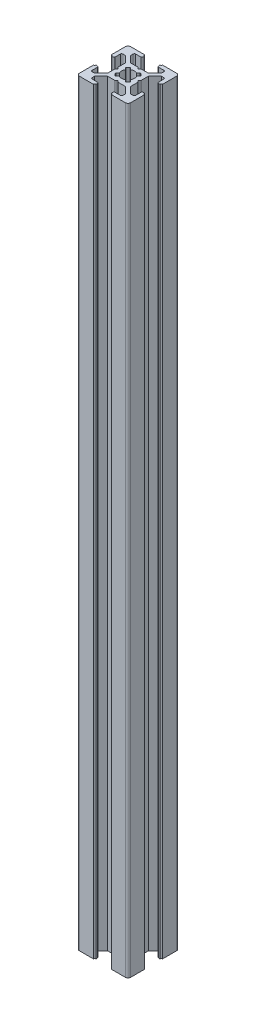
from build123d import *

# Parameters (mm, degrees)
BOSS_EXTRUDE1_DEPTH = 296
FILLET1_R           = 1
CUT_EXTRUDE1_DEPTH  = 297
FILLET2_R           = 0.5
FILLET3_R           = 0.25


with BuildPart() as part:
    # Sketch3 → Boss-Extrude1 (new body)
    with BuildSketch(Plane(origin=(0, 0, 0), x_dir=(1, 0, 0), z_dir=(0, 1, 0))):
        with BuildLine():
            Line((7, 18.5), (7, 19.5))
            ThreePointArc((7, 19.5), (6.646446609, 19.646446609), (6.5, 20))
            Line((6.5, 20), (0, 20))
            Line((0, 20), (0, 13.5))
            ThreePointArc((0, 13.5), (0.353553391, 13.353553391), (0.5, 13))
            Line((0.5, 13), (1.5, 13))
            Line((1.5, 13), (1.5, 16))
            Line((1.5, 16), (3, 16))
            Line((3, 16), (5.5, 13.5))
            Line((5.5, 13.5), (5.5, 10.5))
            Line((5.5, 10.5), (6, 10))
            Line((6, 10), (5.5, 9.5))
            Line((5.5, 9.5), (5.5, 6.5))
            Line((5.5, 6.5), (3, 4))
            Line((3, 4), (1.5, 4))
            Line((1.5, 4), (1.5, 7))
            Line((1.5, 7), (0.5, 7))
            ThreePointArc((0.5, 7), (0.353553391, 6.646446609), (0, 6.5))
            Line((0, 6.5), (0, 0))
            Line((0, 0), (6.5, 0))
            ThreePointArc((6.5, 0), (6.646446609, 0.353553391), (7, 0.5))
            Line((7, 0.5), (7, 1.5))
            Line((7, 1.5), (4, 1.5))
            Line((4, 1.5), (4, 3))
            Line((4, 3), (6.5, 5.5))
            Line((6.5, 5.5), (9.5, 5.5))
            Line((9.5, 5.5), (10, 6))
            Line((10, 6), (10.5, 5.5))
            Line((10.5, 5.5), (13.5, 5.5))
            Line((13.5, 5.5), (16, 3))
            Line((16, 3), (16, 1.5))
            Line((16, 1.5), (13, 1.5))
            Line((13, 1.5), (13, 0.5))
            ThreePointArc((13, 0.5), (13.353553391, 0.353553391), (13.5, 0))
            Line((13.5, 0), (20, 0))
            Line((20, 0), (20, 6.5))
            ThreePointArc((20, 6.5), (19.646446609, 6.646446609), (19.5, 7))
            Line((19.5, 7), (18.5, 7))
            Line((18.5, 7), (18.5, 4))
            Line((18.5, 4), (17, 4))
            Line((17, 4), (14.5, 6.5))
            Line((14.5, 6.5), (14.5, 9.5))
            Line((14.5, 9.5), (14, 10))
            Line((14, 10), (14.5, 10.5))
            Line((14.5, 10.5), (14.5, 13.5))
            Line((14.5, 13.5), (17, 16))
            Line((17, 16), (18.5, 16))
            Line((18.5, 16), (18.5, 13))
            Line((18.5, 13), (19.5, 13))
            ThreePointArc((19.5, 13), (19.646446609, 13.353553391), (20, 13.5))
            Line((20, 13.5), (20, 20))
            Line((20, 20), (13.5, 20))
            ThreePointArc((13.5, 20), (13.353553391, 19.646446609), (13, 19.5))
            Line((13, 19.5), (13, 18.5))
            Line((13, 18.5), (16, 18.5))
            Line((16, 18.5), (16, 17))
            Line((16, 17), (13.5, 14.5))
            Line((13.5, 14.5), (10.5, 14.5))
            Line((10.5, 14.5), (10, 14))
            Line((10, 14), (9.5, 14.5))
            Line((9.5, 14.5), (6.5, 14.5))
            Line((6.5, 14.5), (4, 17))
            Line((4, 17), (4, 18.5))
            Line((4, 18.5), (7, 18.5))
        make_face()
    extrude(amount=BOSS_EXTRUDE1_DEPTH)

    # Fillet1
    fillet1_edges = [part.edges().sort_by_distance(p)[0] for p in [
        (20, 148, 0),
        (0, 148, 0),
        (0, 148, -20),
        (20, 148, -20),
    ]]
    fillet(fillet1_edges, radius=FILLET1_R)

    # Sketch4 → Cut-Extrude1 (cut, through all)
    with BuildSketch(Plane(origin=(0, 296, 0), x_dir=(1, 0, 0), z_dir=(0, 1, 0))):
        with BuildLine():
            Line((10, 11), (11.195582496, 12.195582496))
            ThreePointArc((11.195582496, 12.195582496), (10, 12.5), (8.804417504, 12.195582496))
            Line((8.804417504, 12.195582496), (10, 11))
        make_face()
        with BuildLine():
            ThreePointArc((12.195582496, 11.195582496), (11.767766953, 11.767766953), (11.195582496, 12.195582496))
            Line((11.195582496, 12.195582496), (10, 11))
            Line((10, 11), (11, 10))
            Line((11, 10), (12.195582496, 11.195582496))
        make_face()
        with BuildLine():
            Line((9, 10), (10, 11))
            Line((10, 11), (8.804417504, 12.195582496))
            ThreePointArc((8.804417504, 12.195582496), (8.232233047, 11.767766953), (7.804417504, 11.195582496))
            Line((7.804417504, 11.195582496), (9, 10))
        make_face()
        Polygon((11, 10), (10, 11), (9, 10), (10, 9), align=None)
        with BuildLine():
            Line((7.804417504, 8.804417504), (9, 10))
            Line((9, 10), (7.804417504, 11.195582496))
            ThreePointArc((7.804417504, 11.195582496), (7.5, 10), (7.804417504, 8.804417504))
        make_face()
        with BuildLine():
            Line((10, 9), (9, 10))
            Line((9, 10), (7.804417504, 8.804417504))
            ThreePointArc((7.804417504, 8.804417504), (8.232233047, 8.232233047), (8.804417504, 7.804417504))
            Line((8.804417504, 7.804417504), (10, 9))
        make_face()
        with BuildLine():
            Line((11.195582496, 7.804417504), (10, 9))
            Line((10, 9), (8.804417504, 7.804417504))
            ThreePointArc((8.804417504, 7.804417504), (10, 7.5), (11.195582496, 7.804417504))
        make_face()
        with BuildLine():
            Line((12.195582496, 8.804417504), (11, 10))
            Line((11, 10), (10, 9))
            Line((10, 9), (11.195582496, 7.804417504))
            ThreePointArc((11.195582496, 7.804417504), (11.767766953, 8.232233047), (12.195582496, 8.804417504))
        make_face()
        with BuildLine():
            ThreePointArc((12.5, 10), (12.422700584, 10.616864556), (12.195582496, 11.195582496))
            Line((12.195582496, 11.195582496), (11, 10))
            Line((11, 10), (12.195582496, 8.804417504))
            ThreePointArc((12.195582496, 8.804417504), (12.422700584, 9.383135444), (12.5, 10))
        make_face()
        with BuildLine():
            ThreePointArc((8.804417504, 7.804417504), (8.232233047, 8.232233047), (7.804417504, 8.804417504))
            Line((7.804417504, 8.804417504), (7, 8))
            Line((7, 8), (8, 7))
            Line((8, 7), (8.804417504, 7.804417504))
        make_face()
        with BuildLine():
            Line((13, 8), (12.195582496, 8.804417504))
            ThreePointArc((12.195582496, 8.804417504), (11.767766953, 8.232233047), (11.195582496, 7.804417504))
            Line((11.195582496, 7.804417504), (12, 7))
            Line((12, 7), (13, 8))
        make_face()
        with BuildLine():
            Line((13, 12), (12, 13))
            Line((12, 13), (11.195582496, 12.195582496))
            ThreePointArc((11.195582496, 12.195582496), (11.767766953, 11.767766953), (12.195582496, 11.195582496))
            Line((12.195582496, 11.195582496), (13, 12))
        make_face()
        with BuildLine():
            ThreePointArc((7.804417504, 11.195582496), (8.232233047, 11.767766953), (8.804417504, 12.195582496))
            Line((8.804417504, 12.195582496), (8, 13))
            Line((8, 13), (7, 12))
            Line((7, 12), (7.804417504, 11.195582496))
        make_face()
    extrude(amount=-CUT_EXTRUDE1_DEPTH, mode=Mode.SUBTRACT)

    # Fillet2
    fillet2_edges = [part.edges().sort_by_distance(p)[0] for p in [
        (18.5, 148, -13),
        (18.5, 148, -16),
        (14.5, 148, -10.5),
        (14.5, 148, -9.5),
        (18.5, 148, -4),
        (18.5, 148, -7),
        (13, 148, -1.5),
        (16, 148, -1.5),
        (10.5, 148, -5.5),
        (9.5, 148, -5.5),
        (4, 148, -1.5),
        (7, 148, -1.5),
        (1.5, 148, -7),
        (1.5, 148, -4),
        (5.5, 148, -9.5),
        (5.5, 148, -10.5),
        (1.5, 148, -16),
        (1.5, 148, -13),
        (7, 148, -18.5),
        (4, 148, -18.5),
        (9.5, 148, -14.5),
        (10.5, 148, -14.5),
        (16, 148, -18.5),
        (13, 148, -18.5),
    ]]
    fillet(fillet2_edges, radius=FILLET2_R)

    # Fillet3
    fillet3_edges = [part.edges().sort_by_distance(p)[0] for p in [
        (7, 148, -12),
        (8, 148, -13),
        (12, 148, -13),
        (13, 148, -12),
        (13, 148, -8),
        (12, 148, -7),
        (8, 148, -7),
        (7, 148, -8),
    ]]
    fillet(fillet3_edges, radius=FILLET3_R)


solid = part.part
